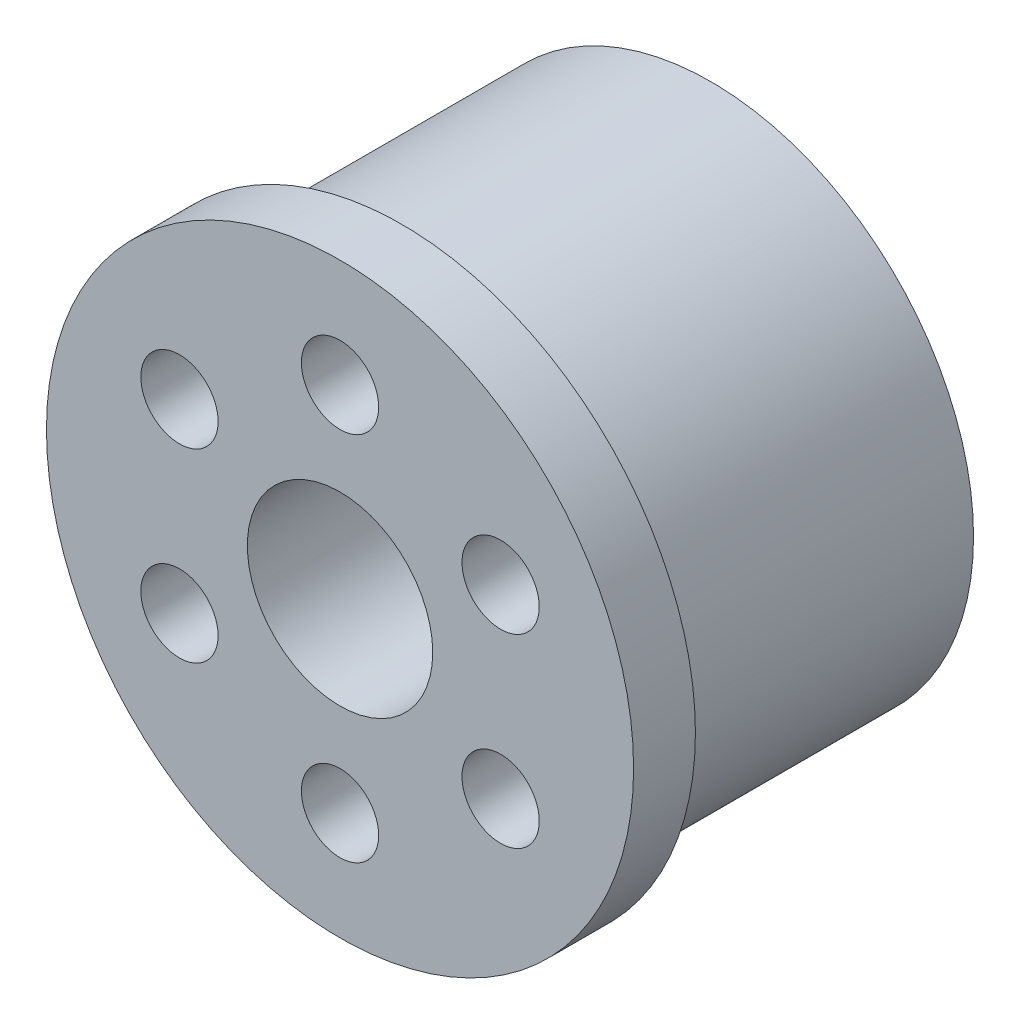
from build123d import *

# Parameters (mm, degrees)
SKETCH1_R             = 8.5
SKETCH1_R_2           = 7.5
BOSS_EXTRUDE1_DEPTH   = 6
SKETCH1_R_3           = 4.5
SKETCH1_R_4           = 3
BOSS_EXTRUDE1_2_DEPTH = 6
BOSS_EXTRUDE12_START  = 6
SKETCH1_4_R           = 9.5
SKETCH1_4_R_2         = 8.5
SKETCH1_4_R_3         = 7.5
SKETCH1_4_R_4         = 4.5
BOSS_EXTRUDE12_DEPTH  = 2
SKETCH1_5_R           = 1.25
CUT_EXTRUDE2_DEPTH    = 15.71393897
CIRPATTERN1_COUNT     = 6


with BuildPart() as part:
    # Sketch1 → Boss-Extrude1 (new, symmetric)
    with BuildSketch(Plane.XY):
        Circle(SKETCH1_R)
        Circle(SKETCH1_R_2, mode=Mode.SUBTRACT)
    extrude(amount=BOSS_EXTRUDE1_DEPTH, both=True)



with BuildPart() as body_2:
    # Sketch1 → Boss-Extrude1 2 (new, symmetric)
    with BuildSketch(Plane.XY):
        Circle(SKETCH1_R_3)
        Circle(SKETCH1_R_4, mode=Mode.SUBTRACT)
    extrude(amount=BOSS_EXTRUDE1_2_DEPTH, both=True)


with BuildPart() as part_1:
    add(part.part)

    add(body_2.part)  # Boss-Extrude12 merges body 2
    # Sketch1_4 → Boss-Extrude12 (add)
    # profile 1 of 2: a face of its own
    with BuildSketch(Plane.XY.offset(BOSS_EXTRUDE12_START)):
        Circle(SKETCH1_4_R)
        Circle(SKETCH1_4_R_2, mode=Mode.SUBTRACT)
    # profile 2 of 2: a face of its own
    with BuildSketch(Plane.XY.offset(BOSS_EXTRUDE12_START)):
        Circle(SKETCH1_4_R_3)
        Circle(SKETCH1_4_R_4, mode=Mode.SUBTRACT)
    extrude(amount=-BOSS_EXTRUDE12_DEPTH)

    # Sketch1_5 → Cut-Extrude2 (cut, symmetric)
    with BuildSketch(Plane.XY):
        with Locations((0, -6)):
            Circle(SKETCH1_5_R)
    cut_extrude2 = extrude(amount=CUT_EXTRUDE2_DEPTH, both=True, mode=Mode.SUBTRACT)

    # CirPattern1: Cut-Extrude2 ×6 about axis
    cirpattern1_axis = Axis((0, 0, 6), (0, 0, 1))
    for i in range(1, CIRPATTERN1_COUNT):
        add(cut_extrude2.rotate(cirpattern1_axis, i * 360 / CIRPATTERN1_COUNT), mode=Mode.SUBTRACT)


solid = part_1.part
